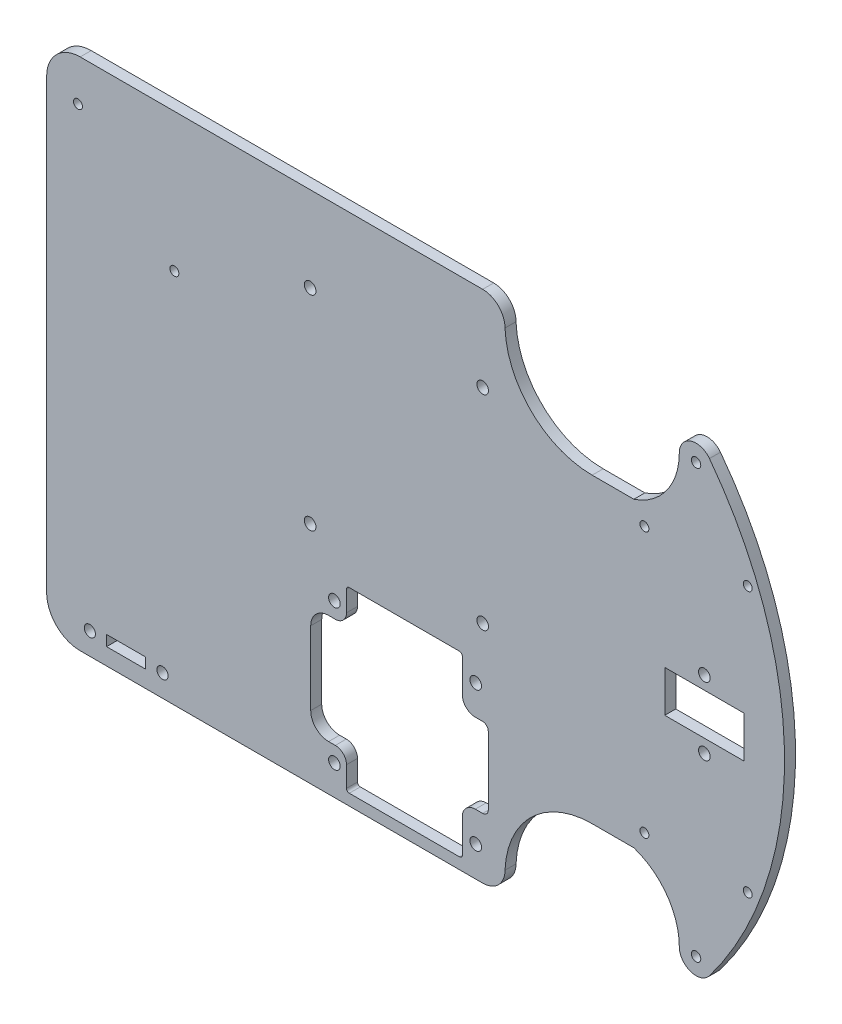
from build123d import *

# Parameters (mm, degrees)
CROQUIS1_W              = 209.55
CROQUIS1_H              = 146.05
SALIENTE_EXTRUIR1_DEPTH = 3.1242
CROQUIS2_R              = 1.3335
CORTAR_EXTRUIR1_DEPTH   = 128.750584639
CROQUIS9_R              = 1.27
CORTAR_EXTRUIR6_DEPTH   = 128.750584639
CORTAR_EXTRUIR2_DEPTH   = 128.750584639
CROQUIS5_R              = 1.651
DRIVER_DEPTH            = 128.750584639
CROQUIS6_R              = 1.651
RASPI_DEPTH             = 128.750584639
CROQUIS8_R              = 1.27
CORTAR_EXTRUIR5_DEPTH   = 128.750584639
CROQUIS7_R              = 1.5875
CROQUIS7_W              = 11.1125
CROQUIS7_H              = 2.9972
CORTAR_EXTRUIR7_DEPTH   = 128.750584639
CROQUIS10_R             = 1.651
CROQUIS10_W             = 22.479
CROQUIS10_H             = 11.7856
CORTAR_EXTRUIR10_DEPTH  = 128.750584639


with BuildPart() as part:
    # Croquis1 → Saliente-Extruir1 (new body)
    with BuildSketch(Plane.XY):
        Rectangle(CROQUIS1_W, CROQUIS1_H)
    extrude(amount=SALIENTE_EXTRUIR1_DEPTH)

    # Croquis2 → Cortar-Extruir1 (cut, through all)
    with BuildSketch(Plane.XY.offset(3.1242)):
        with BuildLine():
            ThreePointArc((80.9879, 60.7314), (80.336840382, 61.877042778), (79.0194, 61.904002767))
            Line((79.0194, 61.904002767), (79.0194, 59.558797233))
            ThreePointArc((79.0194, 59.558797233), (80.336840382, 59.585757222), (80.9879, 60.7314))
        make_face()
        with BuildLine():
            Line((79.0194, 59.558797233), (79.0194, 61.904002767))
            ThreePointArc((79.0194, 61.904002767), (78.3209, 60.7314), (79.0194, 59.558797233))
        make_face()
        with Locations(Location((79.6544, -60.7314, 0), (0, 0, 180))):
            Circle(CROQUIS2_R)
    extrude(amount=-CORTAR_EXTRUIR1_DEPTH, mode=Mode.SUBTRACT)

    # Croquis9 → Cortar-Extruir6 (cut, through all)
    with BuildSketch(Plane.XY.offset(3.1242)):
        with Locations((64.9859, 37.6809)):
            Circle(CROQUIS9_R)
        with Locations((94.3229, 37.6809)):
            Circle(CROQUIS9_R)
        with Locations(Location((94.3229, -37.6809, 0), (0, 0, 180))):
            Circle(CROQUIS9_R)
        with Locations(Location((64.9859, -37.6809, 0), (0, 0, 180))):
            Circle(CROQUIS9_R)
    extrude(amount=-CORTAR_EXTRUIR6_DEPTH, mode=Mode.SUBTRACT)

    # Croquis3 → Cortar-Extruir2 (cut, through all)
    with BuildSketch(Plane.XY.offset(3.1242)):
        with BuildLine():
            ThreePointArc((19.05, 73.025), (23.540128061, 71.165128061), (25.4, 66.675))
            ThreePointArc((25.4, 66.675), (32.974773587, 49.782459091), (50.14595, 42.8625))
            Line((50.14595, 42.8625), (61.988875982, 42.8625))
            ThreePointArc((61.988875982, 42.8625), (71.32896295, 49.711127589), (74.8919, 60.7314))
            ThreePointArc((74.8919, 60.7314), (78.140718752, 65.246948176), (83.454703288, 63.601783453))
            ThreePointArc((83.454703288, 63.601783453), (99.303056378, 33.540057805), (104.775, 0))
            Line((104.775, 0), (104.775, 73.025))
            Line((104.775, 73.025), (19.05, 73.025))
        make_face()
        with BuildLine():
            Line((104.775, -73.025), (104.775, 0))
            ThreePointArc((104.775, 0), (99.303056378, -33.540057805), (83.454703288, -63.601783453))
            ThreePointArc((83.454703288, -63.601783453), (78.140718752, -65.246948176), (74.8919, -60.7314))
            ThreePointArc((74.8919, -60.7314), (71.32896295, -49.711127589), (61.988875982, -42.8625))
            Line((61.988875982, -42.8625), (50.14595, -42.8625))
            ThreePointArc((50.14595, -42.8625), (32.974773587, -49.782459091), (25.4, -66.675))
            ThreePointArc((25.4, -66.675), (23.540128061, -71.165128061), (19.05, -73.025))
            Line((19.05, -73.025), (104.775, -73.025))
        make_face()
        with BuildLine():
            ThreePointArc((-104.775, 63.5), (-101.985192091, 70.235192091), (-95.25, 73.025))
            Line((-95.25, 73.025), (-104.775, 73.025))
            Line((-104.775, 73.025), (-104.775, 63.5))
        make_face()
        with BuildLine():
            Line((-104.775, -73.025), (-95.25, -73.025))
            ThreePointArc((-95.25, -73.025), (-101.985192091, -70.235192091), (-104.775, -63.5))
            Line((-104.775, -63.5), (-104.775, -73.025))
        make_face()
    extrude(amount=-CORTAR_EXTRUIR2_DEPTH, mode=Mode.SUBTRACT)

    # Croquis5 → Driver (cut, through all)
    with BuildSketch(Plane.XY.offset(3.1242)):
        with BuildLine():
            Line((12.47775, -19.2786), (-18.82775, -19.2786))
            ThreePointArc((-18.82775, -19.2786), (-19.389016008, -19.511083992), (-19.6215, -20.07235))
            Line((-19.6215, -20.07235), (-19.6215, -25.8826))
            ThreePointArc((-19.6215, -25.8826), (-20.55143597, -28.12766403), (-22.7965, -29.0576))
            Line((-22.7965, -29.0576), (-24.7015, -29.0576))
            ThreePointArc((-24.7015, -29.0576), (-28.293602448, -30.545497552), (-29.7815, -34.1376))
            Line((-29.7815, -34.1376), (-29.7815, -54.991))
            ThreePointArc((-29.7815, -54.991), (-28.293602448, -58.583102448), (-24.7015, -60.071))
            Line((-24.7015, -60.071), (-22.7965, -60.071))
            ThreePointArc((-22.7965, -60.071), (-20.55143597, -61.00093597), (-19.6215, -63.246))
            Line((-19.6215, -63.246), (-19.6215, -69.05625))
            ThreePointArc((-19.6215, -69.05625), (-19.389016008, -69.617516008), (-18.82775, -69.85))
            Line((-18.82775, -69.85), (12.47775, -69.85))
            ThreePointArc((12.47775, -69.85), (13.039016008, -69.617516008), (13.2715, -69.05625))
            Line((13.2715, -69.05625), (13.2715, -59.563))
            ThreePointArc((13.2715, -59.563), (14.350225725, -56.958725725), (16.9545, -55.88))
            Line((16.9545, -55.88), (19.05, -55.88))
            ThreePointArc((19.05, -55.88), (20.172532015, -55.415032015), (20.6375, -54.2925))
            Line((20.6375, -54.2925), (20.6375, -34.8361))
            ThreePointArc((20.6375, -34.8361), (20.172532015, -33.713567985), (19.05, -33.2486))
            Line((19.05, -33.2486), (16.9545, -33.2486))
            ThreePointArc((16.9545, -33.2486), (14.350225725, -32.169874275), (13.2715, -29.5656))
            Line((13.2715, -29.5656), (13.2715, -20.07235))
            ThreePointArc((13.2715, -20.07235), (13.039016008, -19.511083992), (12.47775, -19.2786))
        make_face()
        with Locations((17.0815, -24.7396)):
            Circle(CROQUIS5_R)
        with Locations((-23.0505, -24.6126)):
            Circle(CROQUIS5_R)
        with Locations(Location((17.0815, -64.389, 0), (0, 0, 180))):
            Circle(CROQUIS5_R)
        with Locations(Location((-23.0505, -64.516, 0), (0, 0, 180))):
            Circle(CROQUIS5_R)
    extrude(amount=-DRIVER_DEPTH, mode=Mode.SUBTRACT)

    # Croquis6 → RasPi (cut, through all)
    with BuildSketch(Plane.XY.offset(3.1242)):
        with Locations((-29.95, 48.8814)):
            Circle(CROQUIS6_R)
        with Locations((19.05, 48.8814)):
            Circle(CROQUIS6_R)
        with Locations((19.05, -9.1186)):
            Circle(CROQUIS6_R)
        with Locations((-29.95, -9.1186)):
            Circle(CROQUIS6_R)
    extrude(amount=-RASPI_DEPTH, mode=Mode.SUBTRACT)

    # Croquis8 → Cortar-Extruir5 (cut, through all)
    with BuildSketch(Plane.XY.offset(3.1242)):
        with Locations((-95.885, 61.138037406)):
            Circle(CROQUIS8_R)
        with Locations((-68.495218831, 33.748256237)):
            Circle(CROQUIS8_R)
    extrude(amount=-CORTAR_EXTRUIR5_DEPTH, mode=Mode.SUBTRACT)

    # Croquis7 → Cortar-Extruir7 (cut, through all)
    with BuildSketch(Plane.XY.offset(3.1242)):
        with Locations((-92.508859415, -66.7639)):
            Circle(CROQUIS7_R)
        with Locations((-71.871359415, -66.7639)):
            Circle(CROQUIS7_R)
        with Locations((-82.190109415, -66.7639)):
            Rectangle(CROQUIS7_W, CROQUIS7_H)
    extrude(amount=-CORTAR_EXTRUIR7_DEPTH, mode=Mode.SUBTRACT)

    # Croquis10 → Cortar-Extruir10 (cut, through all)
    with BuildSketch(Plane.XY.offset(3.1242)):
        with Locations((82.0039, 9.652)):
            Circle(CROQUIS10_R)
        with Locations((82.0039, 0)):
            Rectangle(CROQUIS10_W, CROQUIS10_H)
        with Locations((82.0039, -9.652)):
            Circle(CROQUIS10_R)
    extrude(amount=-CORTAR_EXTRUIR10_DEPTH, mode=Mode.SUBTRACT)


solid = part.part
